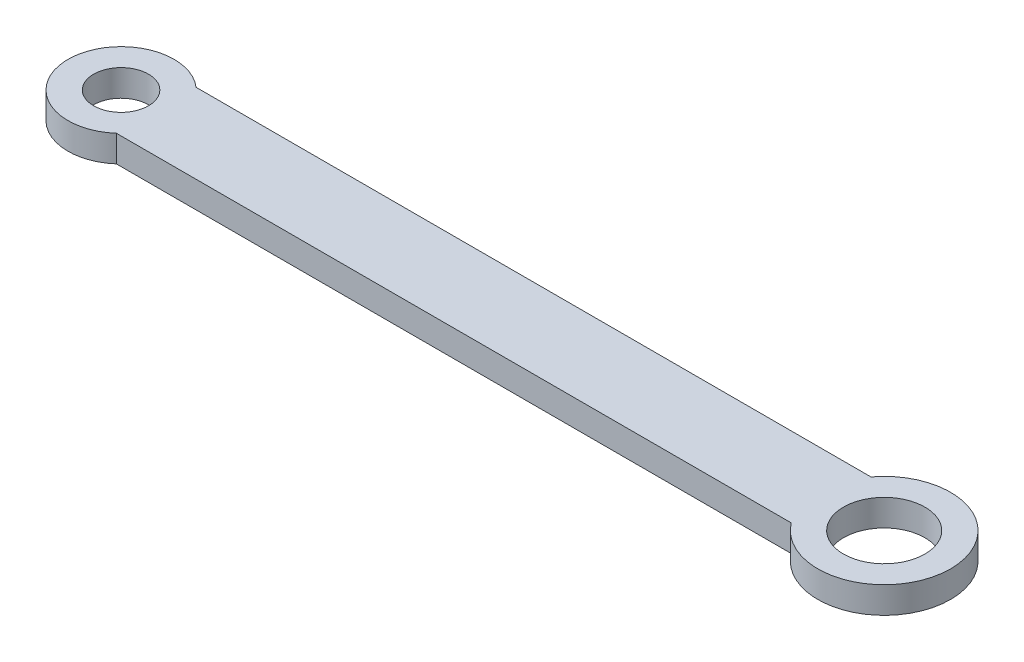
from build123d import *

# Parameters (mm, degrees)
SKETCH1_R           = 3.1
SKETCH1_R_2         = 4.6
BOSS_EXTRUDE1_DEPTH = 3


with BuildPart() as part:
    # Sketch1 → Boss-Extrude1 (new body)
    with BuildSketch(Plane(origin=(0, 0, 0), x_dir=(1, 0, 0), z_dir=(0, 1, 0))):
        with BuildLine():
            ThreePointArc((3.968626967, 4.5), (-6, 0), (3.968626967, -4.5))
            Line((3.968626967, -4.5), (80.23, -4.5))
            ThreePointArc((80.23, -4.5), (93.73, 0), (80.23, 4.5))
            Line((80.23, 4.5), (3.968626967, 4.5))
        make_face()
        Circle(SKETCH1_R, mode=Mode.SUBTRACT)
        with Locations((86.23, 0)):
            Circle(SKETCH1_R_2, mode=Mode.SUBTRACT)
    extrude(amount=BOSS_EXTRUDE1_DEPTH)


solid = part.part
